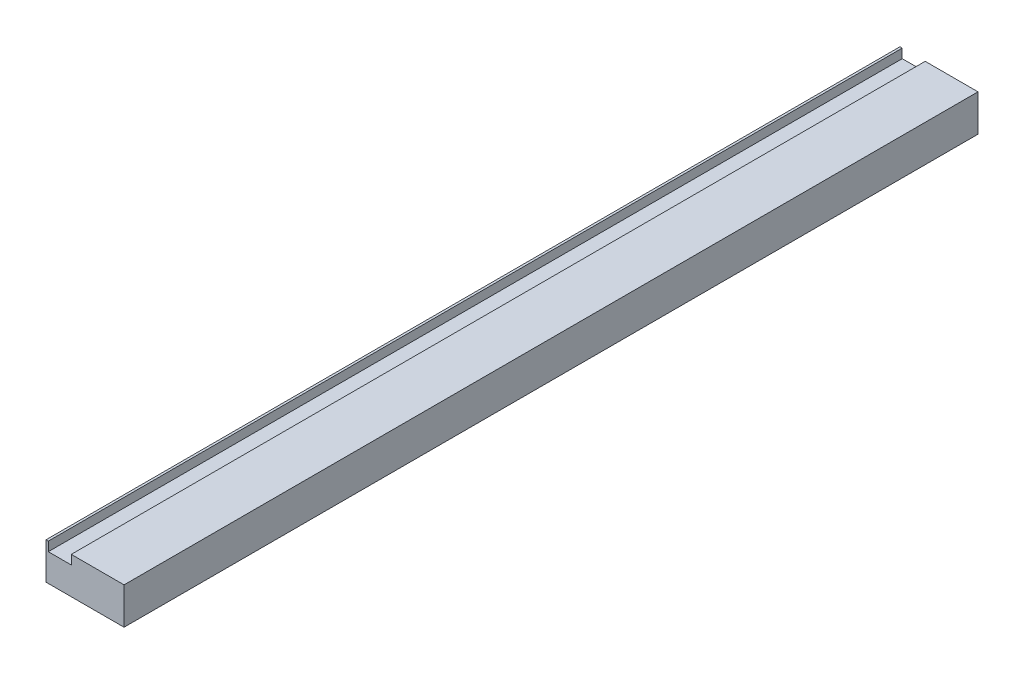
from build123d import *

# Parameters (mm, degrees)
SKETCH1_W           = 15
SKETCH1_H           = 465
BOSS_EXTRUDE1_DEPTH = 20
SKETCH2_W           = 12.5
SKETCH2_H           = 465
CUT_EXTRUDE1_DEPTH  = 5
SKETCH4_W           = 465
SKETCH4_H           = 20
BOSS_EXTRUDE3_DEPTH = 27.5


with BuildPart() as part:
    # Sketch1 → Boss-Extrude1 (new body)
    with BuildSketch(Plane(origin=(0, 0, 0), x_dir=(1, 0, 0), z_dir=(0, 1, 0))):
        Rectangle(SKETCH1_W, SKETCH1_H)
    extrude(amount=BOSS_EXTRUDE1_DEPTH)

    # Sketch2 → Cut-Extrude1 (cut)
    with BuildSketch(Plane(origin=(0, 20, 0), x_dir=(1, 0, 0), z_dir=(0, 1, 0))):
        Rectangle(SKETCH2_W, SKETCH2_H)
    extrude(amount=-CUT_EXTRUDE1_DEPTH, mode=Mode.SUBTRACT)

    # Sketch4 → Boss-Extrude3 (add)
    with BuildSketch(Plane.ZY.offset(-7.5)):
        with Locations((0, 10)):
            Rectangle(SKETCH4_W, SKETCH4_H)
    extrude(amount=-BOSS_EXTRUDE3_DEPTH)


solid = part.part
